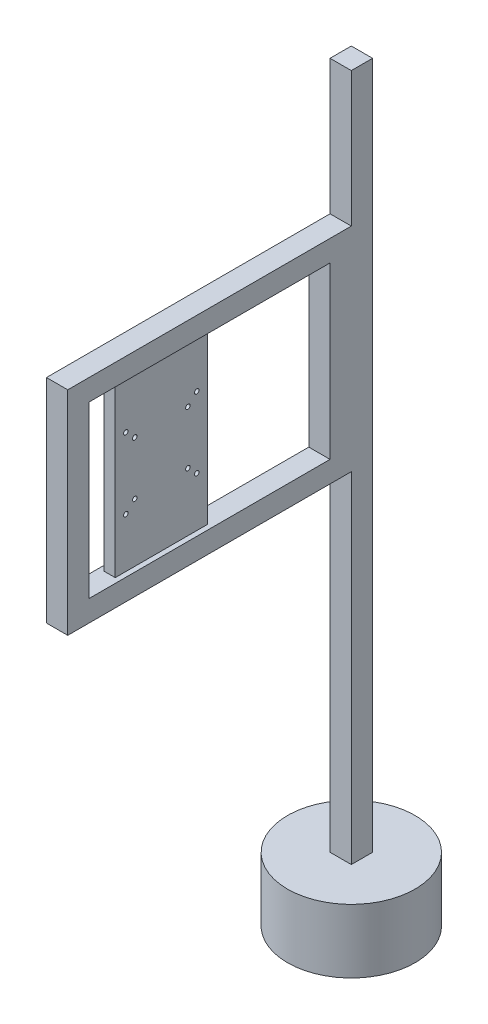
from build123d import *

# Parameters (mm, degrees)
SKETCH_1_R          = 90
EXTRUDE_1_DEPTH     = 90
SKETCH_2_W          = 30
SKETCH_2_H          = 30
EXTRUDE_2_DEPTH     = 970
SKETCH_3_W          = 30
SKETCH_3_H          = 30
EXTRUDE_3_DEPTH     = 200
SKETCH_5_W          = 400
SKETCH_5_H          = 300
SKETCH_5_W_2        = 340
SKETCH_5_H_2        = 240
EXTRUDE_5_DEPTH     = 30
SKETCH_7_W          = 130
SKETCH_7_H          = 240
SKETCH_7_R          = 3.175
EXTRUDE_6_DEPTH     = 30
SKETCH_8_W          = 130
SKETCH_8_H          = 240
CUT_EXTRUDE_1_DEPTH = 7
SKETCH_9_W          = 130
SKETCH_9_H          = 240
CUT_EXTRUDE_2_DEPTH = 7


with BuildPart() as part:
    # 草圖1 → 填料-伸長1 (new body)
    with BuildSketch(Plane(origin=(0, 0, 0), x_dir=(1, 0, 0), z_dir=(0, 1, 0))):
        Circle(SKETCH_1_R)
    extrude(amount=EXTRUDE_1_DEPTH)

    # 草圖2 → 填料-伸長2 (add)
    with BuildSketch(Plane(origin=(0, 90, 0), x_dir=(1, 0, 0), z_dir=(0, 1, 0))):
        Rectangle(SKETCH_2_W, SKETCH_2_H)
    extrude(amount=EXTRUDE_2_DEPTH)

    # 草圖3 → 填料-伸長3 (add)
    with BuildSketch(Plane(origin=(0, 0, 0), x_dir=(-0.707106781, 0, 0.707106781), z_dir=(-0.707106781, 0, -0.707106781))):
        with Locations((0, 195)):
            Rectangle(SKETCH_3_W, SKETCH_3_H)
    extrude(amount=EXTRUDE_3_DEPTH)

    # 草圖5 → 填料-伸長5 (add)
    with BuildSketch(Plane(origin=(15, 0, 0), x_dir=(0, 0, -1), z_dir=(1, 0, 0))):
        with Locations((-215, 720)):
            Rectangle(SKETCH_5_W, SKETCH_5_H)
        with Locations((-215, 720)):
            Rectangle(SKETCH_5_W_2, SKETCH_5_H_2, mode=Mode.SUBTRACT)
    extrude(amount=-EXTRUDE_5_DEPTH)

    # 草圖7 → 填料-伸長6 (add)
    with BuildSketch(Plane.ZY.offset(15)):
        with Locations((276, 720)):
            Rectangle(SKETCH_7_W, SKETCH_7_H)
        with Locations((313.5, 757.5)):
            Circle(SKETCH_7_R, mode=Mode.SUBTRACT)
        with Locations((238.5, 757.5)):
            Circle(SKETCH_7_R, mode=Mode.SUBTRACT)
        with Locations((238.5, 682.5)):
            Circle(SKETCH_7_R, mode=Mode.SUBTRACT)
        with Locations((313.5, 682.5)):
            Circle(SKETCH_7_R, mode=Mode.SUBTRACT)
        with Locations((326, 770)):
            Circle(SKETCH_7_R, mode=Mode.SUBTRACT)
        with Locations((226, 770)):
            Circle(SKETCH_7_R, mode=Mode.SUBTRACT)
        with Locations((326, 670)):
            Circle(SKETCH_7_R, mode=Mode.SUBTRACT)
        with Locations((226, 670)):
            Circle(SKETCH_7_R, mode=Mode.SUBTRACT)
    extrude(amount=-EXTRUDE_6_DEPTH)

    # 草圖8 → 除料-伸長1 (cut)
    with BuildSketch(Plane.ZY.offset(15)):
        with Locations((276, 720)):
            Rectangle(SKETCH_8_W, SKETCH_8_H)
    extrude(amount=-CUT_EXTRUDE_1_DEPTH, mode=Mode.SUBTRACT)

    # 草圖9 → 除料-伸長2 (cut)
    with BuildSketch(Plane(origin=(15, 0, 0), x_dir=(0, 0, -1), z_dir=(1, 0, 0))):
        with Locations((-276, 720)):
            Rectangle(SKETCH_9_W, SKETCH_9_H)
    extrude(amount=-CUT_EXTRUDE_2_DEPTH, mode=Mode.SUBTRACT)


solid = part.part
